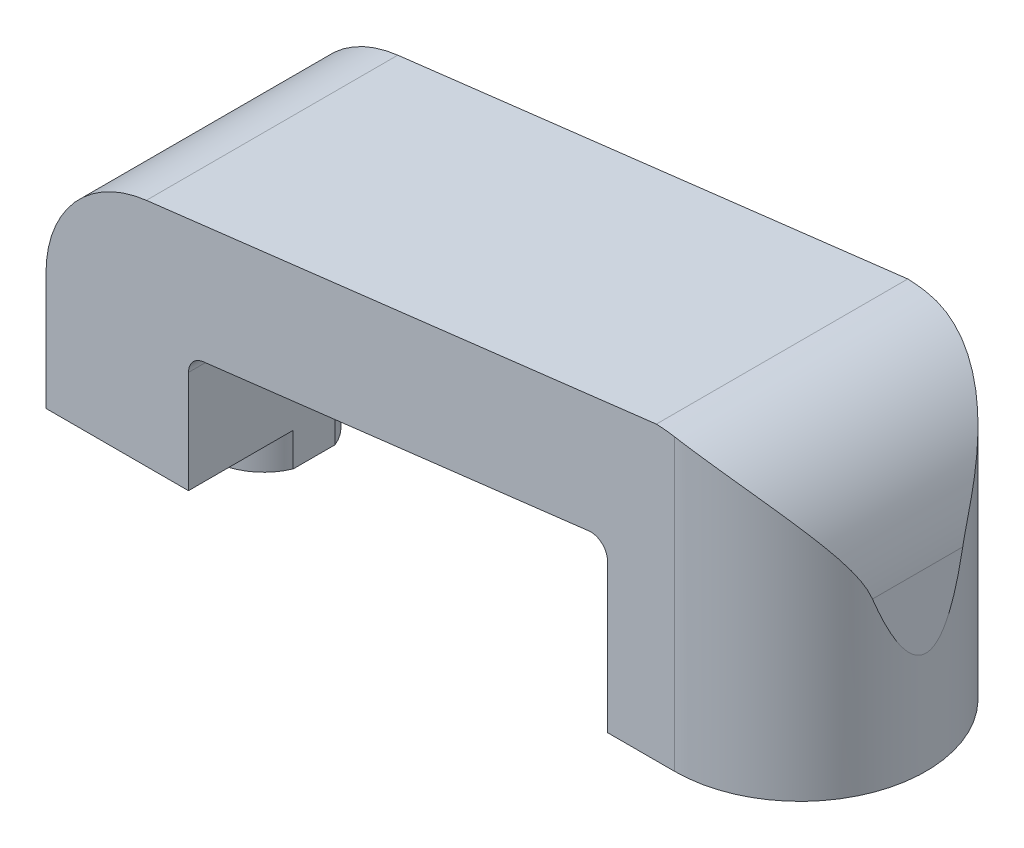
from build123d import *

# Parameters (mm, degrees)
BOSS_EXTRUDE2_DEPTH = 15
CUT_EXTRUDE1_DEPTH  = 25
BOSS_EXTRUDE3_DEPTH = 10
CUT_EXTRUDE2_DEPTH  = 15
SKETCH7_R           = 3.25
SKETCH7_R_2         = 1.25
BOSS_EXTRUDE4_DEPTH = 2
SKETCH9_R           = 1.25
CUT_EXTRUDE3_DEPTH  = 10
SKETCH10_R          = 1.25
CUT_EXTRUDE4_DEPTH  = 1.5


with BuildPart() as part:
    # Sketch3 → Boss-Extrude2 (new body)
    with BuildSketch(Plane.XY):
        with BuildLine():
            Line((0, 0), (-8.5, 0))
            Line((-8.5, 0), (-8.5, 7))
            ThreePointArc((-8.5, 7), (-6.787440348, 11.510881004), (-2.512734375, 13.74869173))
            Line((-2.512734375, 13.74869173), (27.914319597, 17.399938206))
            ThreePointArc((27.914319597, 17.399938206), (33.311410485, 15.179716356), (36, 10))
            Line((36, 10), (36, 0))
            Line((36, 0), (25, 0))
            Line((25, 0), (25, 8.872825735))
            ThreePointArc((25, 8.872825735), (24.663647037, 9.620871596), (23.880854779, 9.865702574))
            Line((23.880854779, 9.865702574), (0.880854779, 7.105702574))
            ThreePointArc((0.880854779, 7.105702574), (0.251954139, 6.776472772), (0, 6.112825735))
            Line((0, 6.112825735), (0, 0))
        make_face()
    extrude(amount=BOSS_EXTRUDE2_DEPTH)

    # Sketch4 → Cut-Extrude1 (cut)
    with BuildSketch(Plane.XZ):
        with BuildLine():
            Line((36, 15), (29, 15))
            ThreePointArc((29, 15), (33.245917567, 13.68240924), (36, 10.192582404))
            Line((36, 10.192582404), (36, 15))
        make_face()
        with BuildLine():
            Line((36, 0), (36, 4.807417596))
            ThreePointArc((36, 4.807417596), (33.245917567, 1.31759076), (29, 0))
            Line((29, 0), (36, 0))
        make_face()
    extrude(amount=-CUT_EXTRUDE1_DEPTH, mode=Mode.SUBTRACT)

    # Sketch5 → Boss-Extrude3 (add)
    with BuildSketch(Plane.XZ):
        with BuildLine():
            ThreePointArc((36, 4.807417596), (36.5, 7.5), (36, 10.192582404))
            Line((36, 10.192582404), (36, 4.807417596))
        make_face()
    extrude(amount=-BOSS_EXTRUDE3_DEPTH)

    # Sketch6 → Cut-Extrude2 (cut)
    with BuildSketch(Plane.XY.offset(15)):
        Polygon((36.5, 10), (36, 10), (36.5, 6.112287873), align=None)
    extrude(amount=-CUT_EXTRUDE2_DEPTH, mode=Mode.SUBTRACT)

    # Sketch7 → Boss-Extrude4 (add)
    with BuildSketch(Plane.XZ):
        with Locations((29, 7.5)):
            Circle(SKETCH7_R)
        with Locations((29, 7.5)):
            Circle(SKETCH7_R_2, mode=Mode.SUBTRACT)
        with BuildLine():
            Line((0, 8.75), (0, 6.25))
            ThreePointArc((0, 6.25), (-6.25, 7.5), (0, 8.75))
        make_face()
        with Locations((-3, 7.5)):
            Circle(SKETCH7_R_2, mode=Mode.SUBTRACT)
    extrude(amount=BOSS_EXTRUDE4_DEPTH)

    # Sketch9 → Cut-Extrude3 (cut)
    with BuildSketch(Plane.XZ.offset(2)):
        with Locations((29, 7.5)):
            Circle(SKETCH9_R)
        with Locations((-3, 7.5)):
            Circle(SKETCH9_R)
    extrude(amount=-CUT_EXTRUDE3_DEPTH, mode=Mode.SUBTRACT)

    # Sketch10 → Cut-Extrude4 (cut)
    with BuildSketch(Plane.XZ.offset(-8)):
        with Locations((29, 7.5)):
            Circle(SKETCH10_R)
    extrude(amount=-CUT_EXTRUDE4_DEPTH, mode=Mode.SUBTRACT)


solid = part.part
